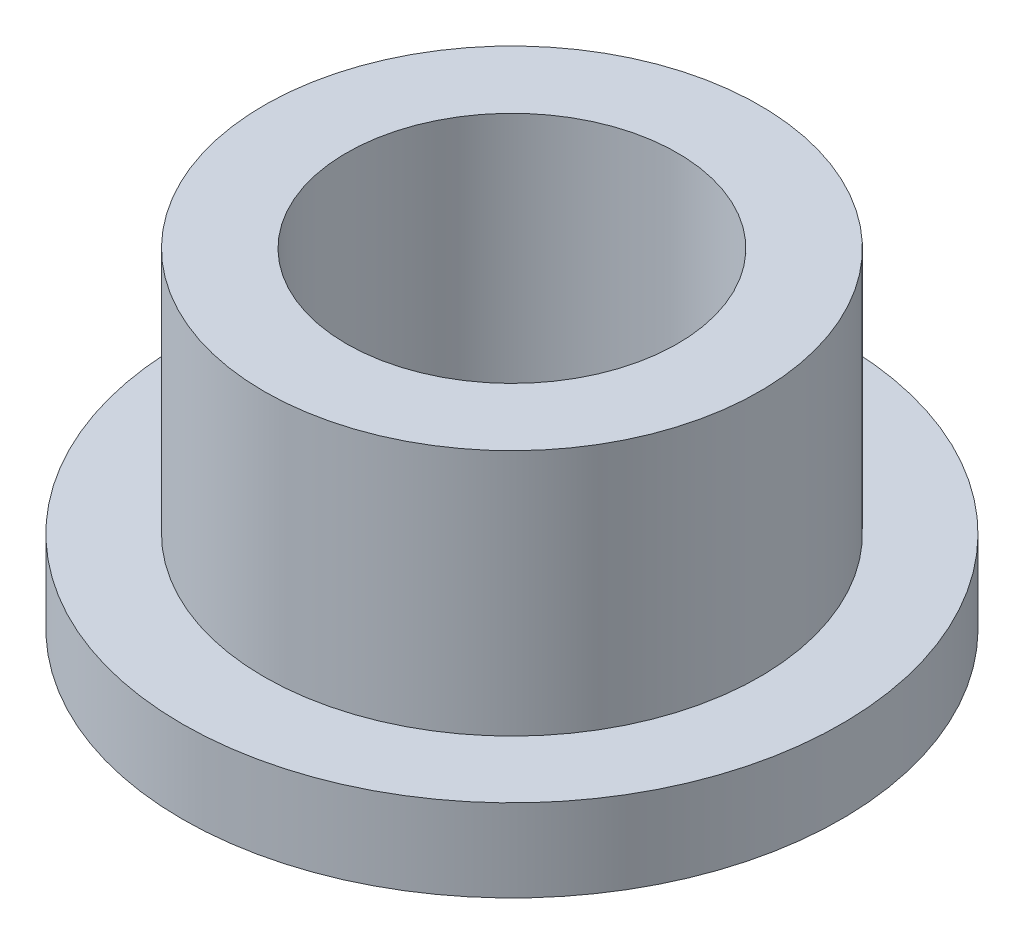
from build123d import *

# Parameters (mm, degrees)
SKETCH2_R           = 9.5504
SKETCH2_R_2         = 6.3754
BOSS_EXTRUDE1_DEPTH = 12.7
SKETCH3_R           = 12.7
SKETCH3_R_2         = 9.5504
BOSS_EXTRUDE2_DEPTH = 3.175


with BuildPart() as part:
    # Sketch2 → Boss-Extrude1 (new body)
    with BuildSketch(Plane(origin=(0, 0, 0), x_dir=(1, 0, 0), z_dir=(0, 1, 0))):
        Circle(SKETCH2_R)
        Circle(SKETCH2_R_2, mode=Mode.SUBTRACT)
    extrude(amount=BOSS_EXTRUDE1_DEPTH)

    # Sketch3 → Boss-Extrude2 (add)
    with BuildSketch(Plane(origin=(0, 0, 0), x_dir=(1, 0, 0), z_dir=(0, 1, 0))):
        Circle(SKETCH3_R)
        Circle(SKETCH3_R_2, mode=Mode.SUBTRACT)
    extrude(amount=BOSS_EXTRUDE2_DEPTH)


solid = part.part
